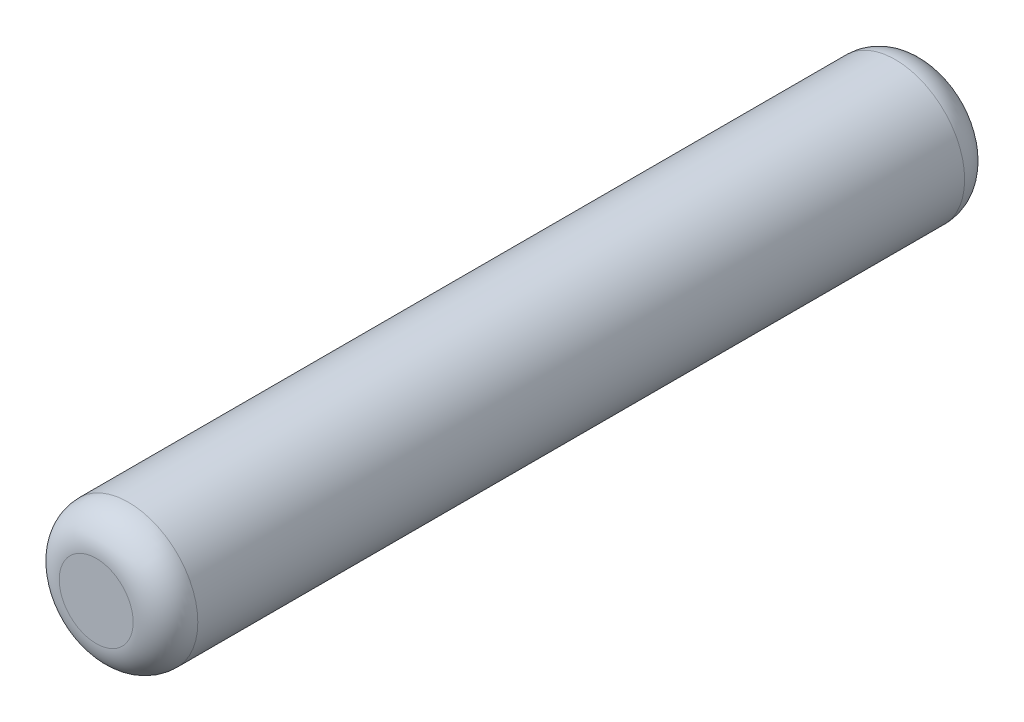
from build123d import *

# Parameters (mm, degrees)
SKETCH1_R           = 0.75
BOSS_EXTRUDE1_DEPTH = 4.5
FILLET1_R           = 0.35


with BuildPart() as part:
    # Sketch1 → Boss-Extrude1 (new body, symmetric)
    with BuildSketch(Plane.XY):
        Circle(SKETCH1_R)
    extrude(amount=BOSS_EXTRUDE1_DEPTH, both=True)

    # Fillet1
    fillet1_edges = [part.edges().sort_by_distance(p)[0] for p in [
        (-0.75, 0, -4.5),
        (-0.75, 0, 4.5),
    ]]
    fillet(fillet1_edges, radius=FILLET1_R)


solid = part.part
